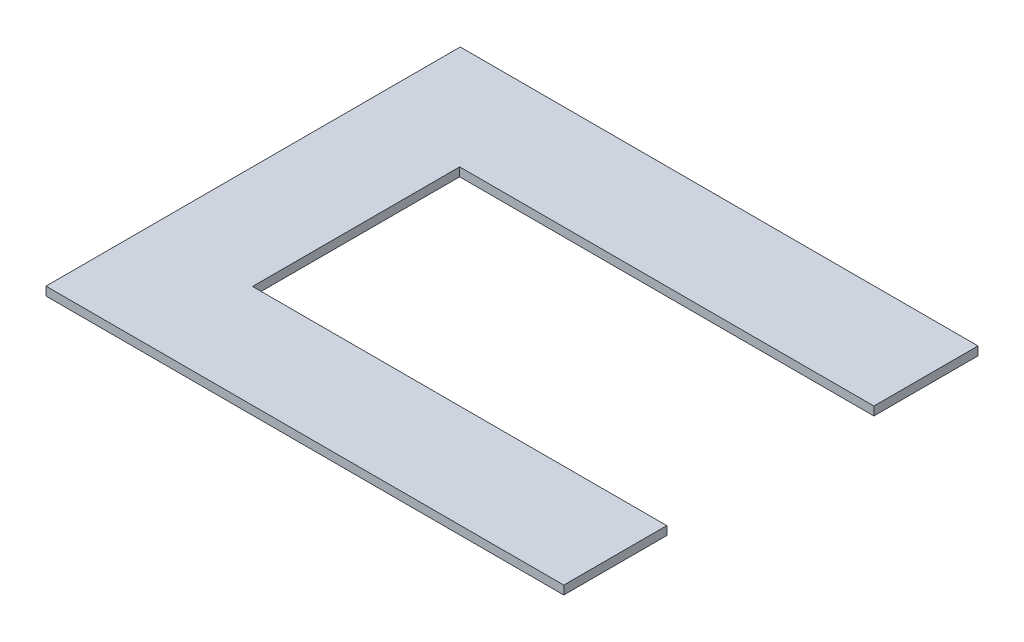
from build123d import *

# Parameters (mm, degrees)
SKETCH1_W           = 381
SKETCH1_H           = 304.8
BOSS_EXTRUDE1_DEPTH = 6.35
SKETCH3_W           = 304.8
SKETCH3_H           = 152.4
CUT_EXTRUDE2_DEPTH  = 6.35


with BuildPart() as part:
    # Sketch1 → Boss-Extrude1 (new body)
    with BuildSketch(Plane(origin=(0, 0, 0), x_dir=(1, 0, 0), z_dir=(0, 1, 0))):
        with Locations((-190.5, 152.4)):
            Rectangle(SKETCH1_W, SKETCH1_H)
    extrude(amount=BOSS_EXTRUDE1_DEPTH)

    # Sketch3 → Cut-Extrude2 (cut)
    with BuildSketch(Plane(origin=(0, 6.35, 0), x_dir=(1, 0, 0), z_dir=(0, 1, 0))):
        with Locations((-152.4, 151.980710276)):
            Rectangle(SKETCH3_W, SKETCH3_H)
    extrude(amount=-CUT_EXTRUDE2_DEPTH, mode=Mode.SUBTRACT)


solid = part.part
